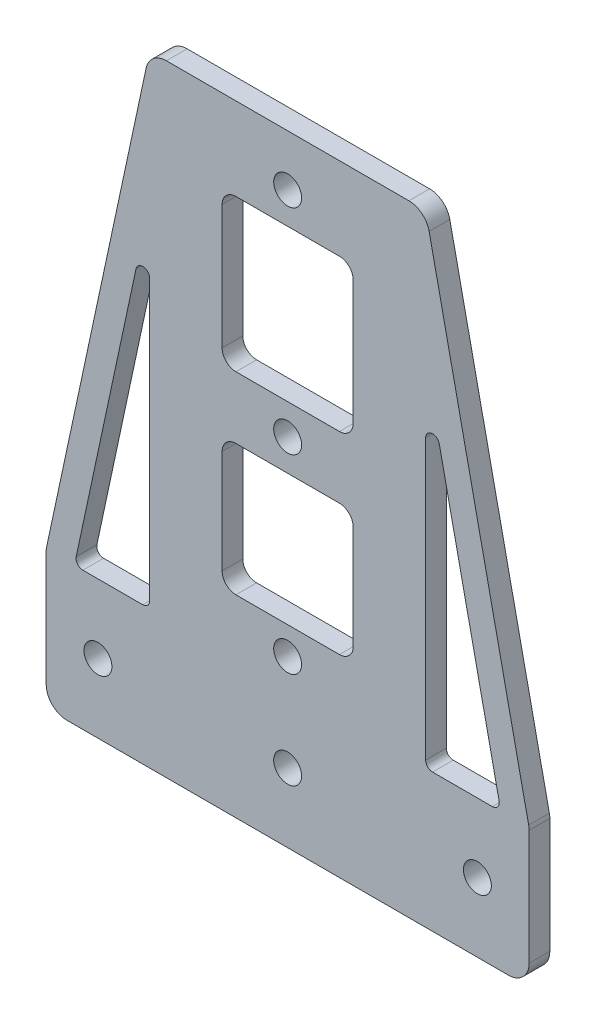
from build123d import *

# Parameters (mm, degrees)
EXTRUDE_1_DEPTH     = 3
SKETCH_3_W          = 19
SKETCH_3_H          = 22
SKETCH_3_H_2        = 19
CUT_EXTRUDE_1_DEPTH = 3
FILLET_1_R          = 1
FILLET_2_R          = 2
FILLET_3_R          = 3
SKETCH_4_R          = 2.025
CUT_EXTRUDE_2_DEPTH = 3
SKETCH_5_R          = 2.025
CUT_EXTRUDE_3_DEPTH = 10


with BuildPart() as part:
    # 草图1 → 凸台-拉伸1 (new body)
    with BuildSketch(Plane.XY):
        Polygon((0, 0), (-70, 0), (-70, 20), (-55, 90), (-15, 90), (0, 20), align=None)
    extrude(amount=EXTRUDE_1_DEPTH)

    # 草图3 → 切除-拉伸1 (cut)
    with BuildSketch(Plane.XY.offset(3)):
        with Locations((-35, 67)):
            Rectangle(SKETCH_3_W, SKETCH_3_H)
        with Locations((-35, 37.5)):
            Rectangle(SKETCH_3_W, SKETCH_3_H_2)
        Polygon((-55, 70.909571916), (-55, 20), (-65.909193982, 20), align=None)
        Polygon((-4.090806018, 20), (-15, 70.909571916), (-15, 20), align=None)
    extrude(amount=-CUT_EXTRUDE_1_DEPTH, mode=Mode.SUBTRACT)

    # 圆角1
    fillet_1_edges = [part.edges().sort_by_distance(p)[0] for p in [
        (-4.090806018, 20, 1.5),
        (-15, 20, 1.5),
        (-15, 70.909571916, 1.5),
        (-65.909193982, 20, 1.5),
        (-55, 70.909571916, 1.5),
        (-55, 20, 1.5),
    ]]
    fillet(fillet_1_edges, radius=FILLET_1_R)

    # 圆角2
    fillet_2_edges = [part.edges().sort_by_distance(p)[0] for p in [
        (-25.5, 47, 1.5),
        (-25.5, 28, 1.5),
        (-44.5, 28, 1.5),
        (-44.5, 47, 1.5),
        (-25.5, 78, 1.5),
        (-25.5, 56, 1.5),
        (-44.5, 56, 1.5),
        (-44.5, 78, 1.5),
    ]]
    fillet(fillet_2_edges, radius=FILLET_2_R)

    # 圆角3
    fillet_3_edges = [part.edges().sort_by_distance(p)[0] for p in [
        (0, 0, 1.5),
        (-70, 0, 1.5),
        (-70, 20, 1.5),
        (-55, 90, 1.5),
        (-15, 90, 1.5),
        (0, 20, 1.5),
    ]]
    fillet(fillet_3_edges, radius=FILLET_3_R)

    # 草图4 → 切除-拉伸2 (cut)
    with BuildSketch(Plane.XY.offset(3)):
        with Locations((-62.5, 10)):
            Circle(SKETCH_4_R)
        with Locations((-35, 10)):
            Circle(SKETCH_4_R)
        with Locations((-7.5, 10)):
            Circle(SKETCH_4_R)
    extrude(amount=-CUT_EXTRUDE_2_DEPTH, mode=Mode.SUBTRACT)

    # 草图5 → 切除-拉伸3 (cut)
    with BuildSketch(Plane(origin=(0, 0, 0), x_dir=(-1, 0, 0), z_dir=(0, 0, -1))):
        with Locations((35, 82.566965626)):
            Circle(SKETCH_5_R)
        with Locations((35, 51.566965626)):
            Circle(SKETCH_5_R)
        with Locations((35, 24)):
            Circle(SKETCH_5_R)
    extrude(amount=-CUT_EXTRUDE_3_DEPTH, mode=Mode.SUBTRACT)


solid = part.part
